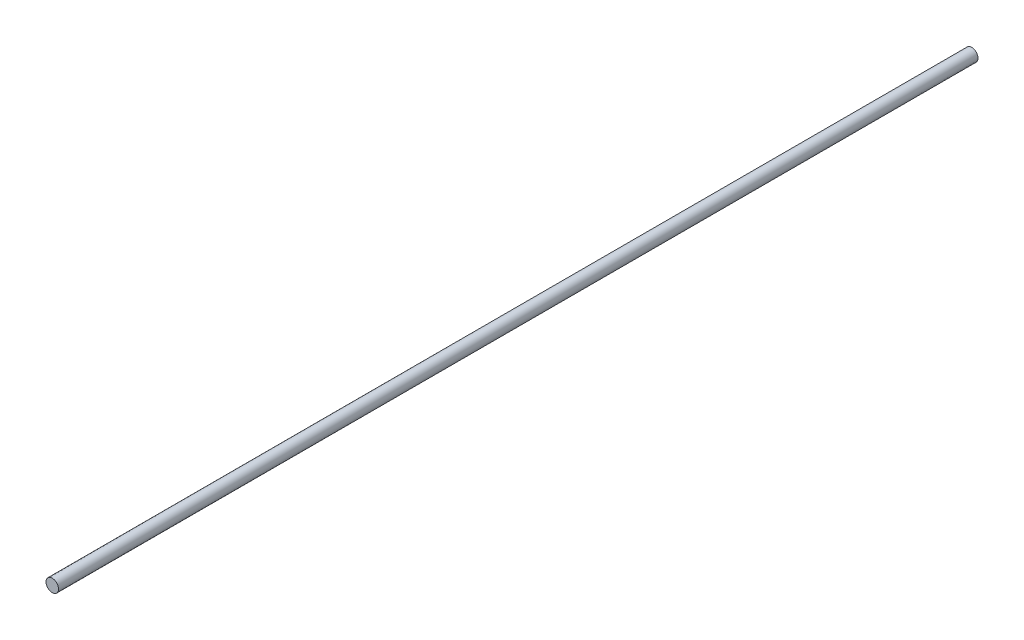
from build123d import *

# Parameters (mm, degrees)
ESQUISSE1_R        = 1.5
BOSS_EXTRU_1_DEPTH = 220


with BuildPart() as part:
    # Esquisse1 → Boss.-Extru.1 (new body)
    with BuildSketch(Plane.XY):
        Circle(ESQUISSE1_R)
    extrude(amount=BOSS_EXTRU_1_DEPTH)


solid = part.part
